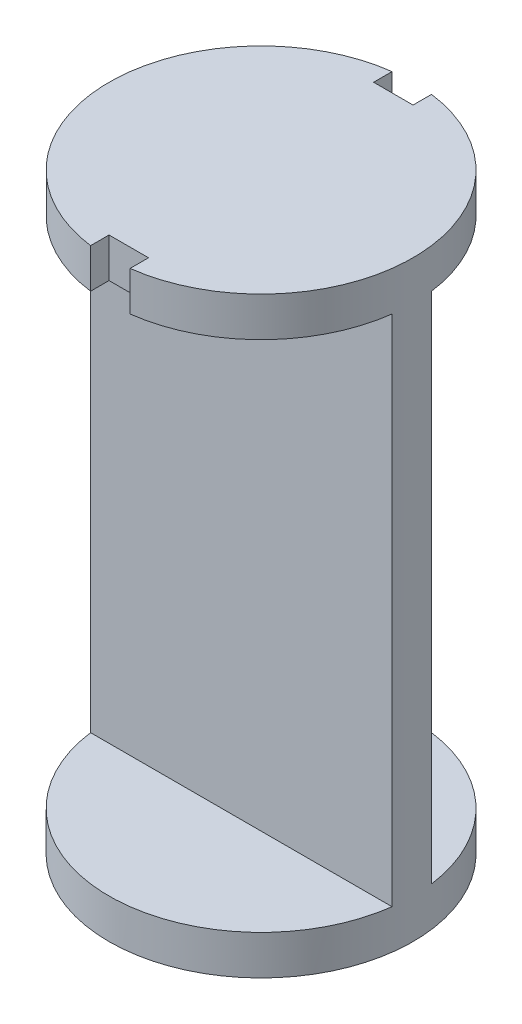
from build123d import *

# Parameters (mm, degrees)
SKETCH1_R           = 38.5
BOSS_EXTRUDE1_DEPTH = 10
SKETCH2_R           = 38.5
BOSS_EXTRUDE2_DEPTH = 10
BOSS_EXTRUDE3_DEPTH = 140
CUT_EXTRUDE1_REACH  = 152
SKETCH4_W           = 10
SKETCH4_H           = 10


with BuildPart() as part:
    # Sketch1 → Boss-Extrude1 (new body)
    with BuildSketch(Plane(origin=(0, 0, 0), x_dir=(1, 0, 0), z_dir=(0, 1, 0))):
        Circle(SKETCH1_R)
    extrude(amount=BOSS_EXTRUDE1_DEPTH)



with BuildPart() as body_2:
    # Sketch2 → Boss-Extrude2 (new body)
    with BuildSketch(Plane(origin=(0, 150, 0), x_dir=(1, 0, 0), z_dir=(0, 1, 0))):
        Circle(SKETCH2_R)
    extrude(amount=-BOSS_EXTRUDE2_DEPTH)


with BuildPart() as part_1:
    add(part.part)

    add(body_2.part)  # Boss-Extrude3 merges body 2
    # Sketch3 → Boss-Extrude3 (add)
    with BuildSketch(Plane(origin=(0, 10, 0), x_dir=(1, 0, 0), z_dir=(0, 1, 0))):
        with BuildLine():
            Line((38.173943993, 5), (-38.173943993, 5))
            ThreePointArc((-38.173943993, 5), (-38.5, 0), (-38.173943993, -5))
            Line((-38.173943993, -5), (38.173943993, -5))
            ThreePointArc((38.173943993, -5), (38.5, 0), (38.173943993, 5))
        make_face()
    extrude(amount=BOSS_EXTRUDE3_DEPTH)

    # Sketch4 → Cut-Extrude1 (cut, up to next)
    with BuildSketch(Plane(origin=(0, 150, 0), x_dir=(1, 0, 0), z_dir=(0, 1, 0)), mode=Mode.PRIVATE) as cut_extrude1_sk1:
        with Locations((0, 38.5)):
            Rectangle(SKETCH4_W, SKETCH4_H)
    cut_extrude1_tool1 = extrude(cut_extrude1_sk1.sketch, amount=-CUT_EXTRUDE1_REACH, mode=Mode.PRIVATE) & part_1.part
    add(cut_extrude1_tool1.solids().sort_by_distance((0, 150, -38.5))[0], mode=Mode.SUBTRACT)
    # Sketch4 → Cut-Extrude1 (cut, up to next)
    with BuildSketch(Plane(origin=(0, 150, 0), x_dir=(1, 0, 0), z_dir=(0, 1, 0)), mode=Mode.PRIVATE) as cut_extrude1_sk2:
        with Locations((0, -38.5)):
            Rectangle(SKETCH4_W, SKETCH4_H)
    cut_extrude1_tool2 = extrude(cut_extrude1_sk2.sketch, amount=-CUT_EXTRUDE1_REACH, mode=Mode.PRIVATE) & part_1.part
    add(cut_extrude1_tool2.solids().sort_by_distance((0, 150, 38.5))[0], mode=Mode.SUBTRACT)


solid = part_1.part
